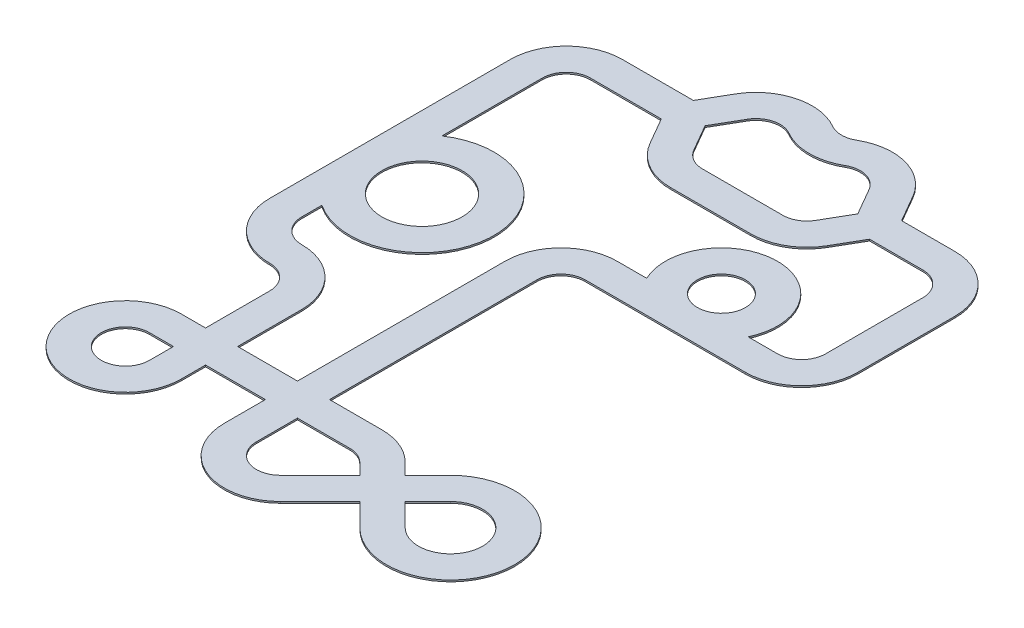
from build123d import *

# Parameters (mm, degrees)
EXTRUDE_1_DEPTH = 20


with BuildPart() as part:
    # 草图1 → 凸台-拉伸1 (new body)
    with BuildSketch(Plane(origin=(0, 0, 0), x_dir=(1, 0, 0), z_dir=(0, 1, 0))):
        with BuildLine():
            Line((500, 700), (1384.529946162, 700))
            Line((1384.529946162, 700), (1576.794919243, 1033.012701892))
            ThreePointArc((1576.794919243, 1033.012701892), (2001.83937032, 1359.160780295), (2533.012701892, 1289.230484541))
            ThreePointArc((2533.012701892, 1289.230484541), (2683.012701892, 1249.038105677), (2833.012701892, 1289.230484541))
            ThreePointArc((2833.012701892, 1289.230484541), (3364.186033464, 1359.160780295), (3789.230484541, 1033.012701892))
            Line((3789.230484541, 1033.012701892), (3981.495457623, 700))
            Line((3981.495457623, 700), (4646.446609407, 700))
            ThreePointArc((4646.446609407, 700), (5141.421356237, 494.974746831), (5346.446609407, 0))
            Line((5346.446609407, 0), (5346.446609407, -1212.132034356))
            ThreePointArc((5346.446609407, -1212.132034356), (5141.421356237, -1707.106781187), (4646.446609407, -1912.132034356))
            Line((4646.446609407, -1912.132034356), (3646.446609407, -1912.132034356))
            Line((3646.446609407, -1912.132034356), (2646.446609407, -1912.132034356))
            ThreePointArc((2646.446609407, -1912.132034356), (2434.314575051, -2000), (2346.446609407, -2212.132034356))
            Line((2346.446609407, -2212.132034356), (2346.446609407, -4800))
            Line((2346.446609407, -4800), (3000, -4800))
            ThreePointArc((3000, -4800), (3267.878402656, -4853.284327242), (3494.974746831, -5005.025253169))
            Line((3494.974746831, -5005.025253169), (3636.396103068, -5146.446609407))
            Line((3636.396103068, -5146.446609407), (3919.238815543, -4863.603896932))
            ThreePointArc((3919.238815543, -4863.603896932), (5284.924240492, -5429.289321881), (3919.238815543, -5994.974746831))
            Line((3919.238815543, -5994.974746831), (3636.396103068, -5712.132034356))
            Line((3636.396103068, -5712.132034356), (3141.421356237, -6207.106781187))
            ThreePointArc((3141.421356237, -6207.106781187), (2378.568206751, -6358.847707114), (1946.446609407, -5712.132034356))
            Line((1946.446609407, -5712.132034356), (1946.446609407, -5200))
            Line((1946.446609407, -5200), (1200, -5200))
            Line((1200, -5200), (1200, -5500))
            ThreePointArc((1200, -5500), (5.025253169, -5994.974746831), (500, -4800))
            Line((500, -4800), (800, -4800))
            Line((800, -4800), (800, -4000))
            ThreePointArc((800, -4000), (712.132034356, -3787.867965644), (500, -3700))
            ThreePointArc((500, -3700), (5.025253169, -3494.974746831), (-200, -3000))
            Line((-200, -3000), (-200, -2000))
            Line((-200, -2000), (-200, 0))
            ThreePointArc((-200, 0), (5.025253169, 494.974746831), (500, 700))
        make_face()
        with BuildLine():
            Line((1730.940107676, 500), (1923.205080757, 833.012701892))
            ThreePointArc((1923.205080757, 833.012701892), (2105.366988361, 972.790449779), (2333.012701892, 942.820323028))
            ThreePointArc((2333.012701892, 942.820323028), (2683.012701892, 849.038105677), (3033.012701892, 942.820323028))
            ThreePointArc((3033.012701892, 942.820323028), (3260.658415423, 972.790449779), (3442.820323028, 833.012701892))
            Line((3442.820323028, 833.012701892), (3635.085296109, 500))
            Line((3635.085296109, 500), (3442.820323028, 166.987298108))
            ThreePointArc((3442.820323028, 166.987298108), (3333.012701893, 57.179676972), (3183.012701893, 16.987298108))
            Line((3183.012701893, 16.987298108), (2183.012701892, 16.987298108))
            ThreePointArc((2183.012701892, 16.987298108), (2033.012701892, 57.179676972), (1923.205080757, 166.987298108))
            Line((1923.205080757, 166.987298108), (1730.940107676, 500))
        make_face(mode=Mode.SUBTRACT)
        with BuildLine():
            Line((1384.529946162, 300), (1576.794919243, -33.012701892))
            ThreePointArc((1576.794919243, -33.012701892), (1833.012701892, -289.230484541), (2183.012701892, -383.012701892))
            Line((2183.012701892, -383.012701892), (3183.012701893, -383.012701892))
            ThreePointArc((3183.012701893, -383.012701892), (3533.012701893, -289.230484541), (3789.230484542, -33.012701892))
            Line((3789.230484542, -33.012701892), (3981.495457623, 300))
            Line((3981.495457623, 300), (4646.446609407, 300))
            ThreePointArc((4646.446609407, 300), (4858.578643763, 212.132034356), (4946.446609407, 0))
            Line((4946.446609407, 0), (4946.446609407, -1212.132034356))
            ThreePointArc((4946.446609407, -1212.132034356), (4858.578643763, -1424.264068712), (4646.446609407, -1512.132034356))
            Line((4646.446609407, -1512.132034356), (4278.90214144, -1512.132034356))
            ThreePointArc((4278.90214144, -1512.132034356), (4238.054587717, -837.966295679), (3646.446609407, -512.132034356))
            ThreePointArc((3646.446609407, -512.132034356), (3054.838631097, -837.966295679), (3013.991077373, -1512.132034356))
            Line((3013.991077373, -1512.132034356), (2646.446609407, -1512.132034356))
            ThreePointArc((2646.446609407, -1512.132034356), (2151.471862576, -1717.157287525), (1946.446609407, -2212.132034356))
            Line((1946.446609407, -2212.132034356), (1946.446609407, -4800))
            Line((1946.446609407, -4800), (1200, -4800))
            Line((1200, -4800), (1200, -4000))
            ThreePointArc((1200, -4000), (994.974746831, -3505.025253169), (500, -3300))
            ThreePointArc((500, -3300), (287.867965644, -3212.132034356), (200, -3000))
            Line((200, -3000), (200, -2748.331477355))
            ThreePointArc((200, -2748.331477355), (1124.264068712, -2793.725393319), (1600, -2000))
            ThreePointArc((1600, -2000), (1124.264068712, -1206.274606681), (200, -1251.668522645))
            Line((200, -1251.668522645), (200, 0))
            ThreePointArc((200, 0), (287.867965644, 212.132034356), (500, 300))
            Line((500, 300), (1384.529946162, 300))
        make_face(mode=Mode.SUBTRACT)
        with BuildLine():
            Line((2858.578643763, -5924.264068712), (3353.553390593, -5429.289321881))
            Line((3353.553390593, -5429.289321881), (3212.132034356, -5287.867965644))
            ThreePointArc((3212.132034356, -5287.867965644), (3114.80502971, -5222.836140247), (3000, -5200))
            Line((3000, -5200), (2346.446609407, -5200))
            Line((2346.446609407, -5200), (2346.446609407, -5712.132034356))
            ThreePointArc((2346.446609407, -5712.132034356), (2531.641579697, -5989.295894109), (2858.578643763, -5924.264068712))
        make_face(mode=Mode.SUBTRACT)
        with BuildLine():
            Line((4202.081528017, -5712.132034356), (3919.238815543, -5429.289321881))
            Line((3919.238815543, -5429.289321881), (4202.081528017, -5146.446609407))
            ThreePointArc((4202.081528017, -5146.446609407), (4884.924240492, -5429.289321881), (4202.081528017, -5712.132034356))
        make_face(mode=Mode.SUBTRACT)
        with BuildLine():
            Line((800, -5500), (800, -5200))
            Line((800, -5200), (500, -5200))
            ThreePointArc((500, -5200), (287.867965644, -5712.132034356), (800, -5500))
        make_face(mode=Mode.SUBTRACT)
        with BuildLine():
            ThreePointArc((3646.446609407, -1512.132034356), (3346.446609407, -1212.132034356), (3646.446609407, -912.132034356))
            ThreePointArc((3646.446609407, -912.132034356), (3946.446609407, -1212.132034356), (3646.446609407, -1512.132034356))
        make_face(mode=Mode.SUBTRACT)
        with BuildLine():
            ThreePointArc((1200, -2000), (700, -2500), (200, -2000))
            ThreePointArc((200, -2000), (700, -1500), (1200, -2000))
        make_face(mode=Mode.SUBTRACT)
    extrude(amount=EXTRUDE_1_DEPTH)


solid = part.part
